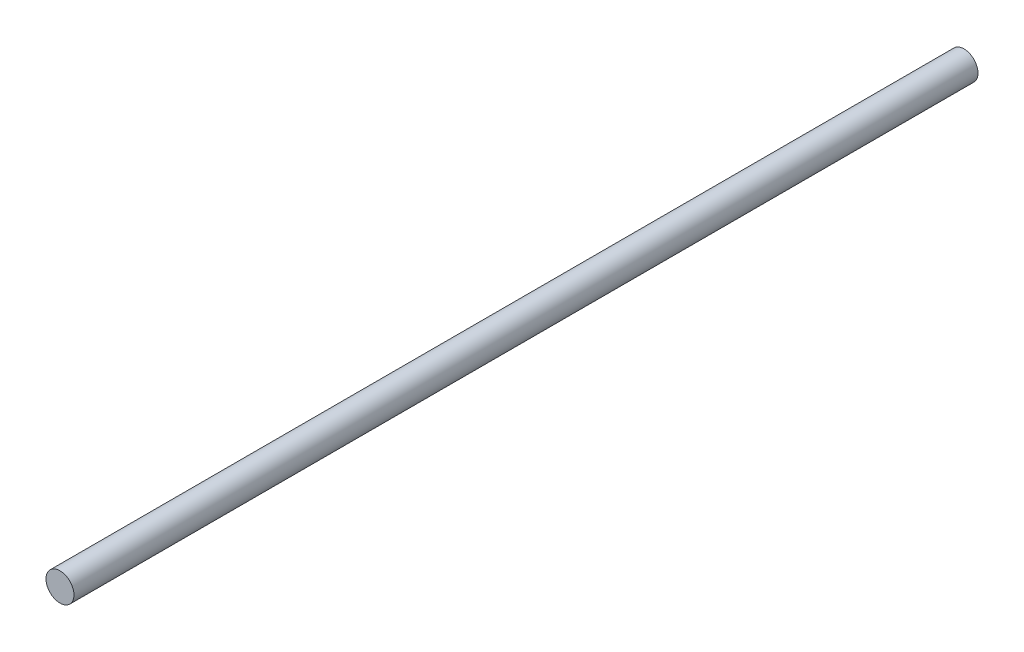
from build123d import *

# Parameters (mm, degrees)
SKETCH1_R           = 5.5
BOSS_EXTRUDE1_DEPTH = 177.5


with BuildPart() as part:
    # Sketch1 → Boss-Extrude1 (new body, symmetric)
    with BuildSketch(Plane.XY):
        Circle(SKETCH1_R)
    extrude(amount=BOSS_EXTRUDE1_DEPTH, both=True)


solid = part.part
